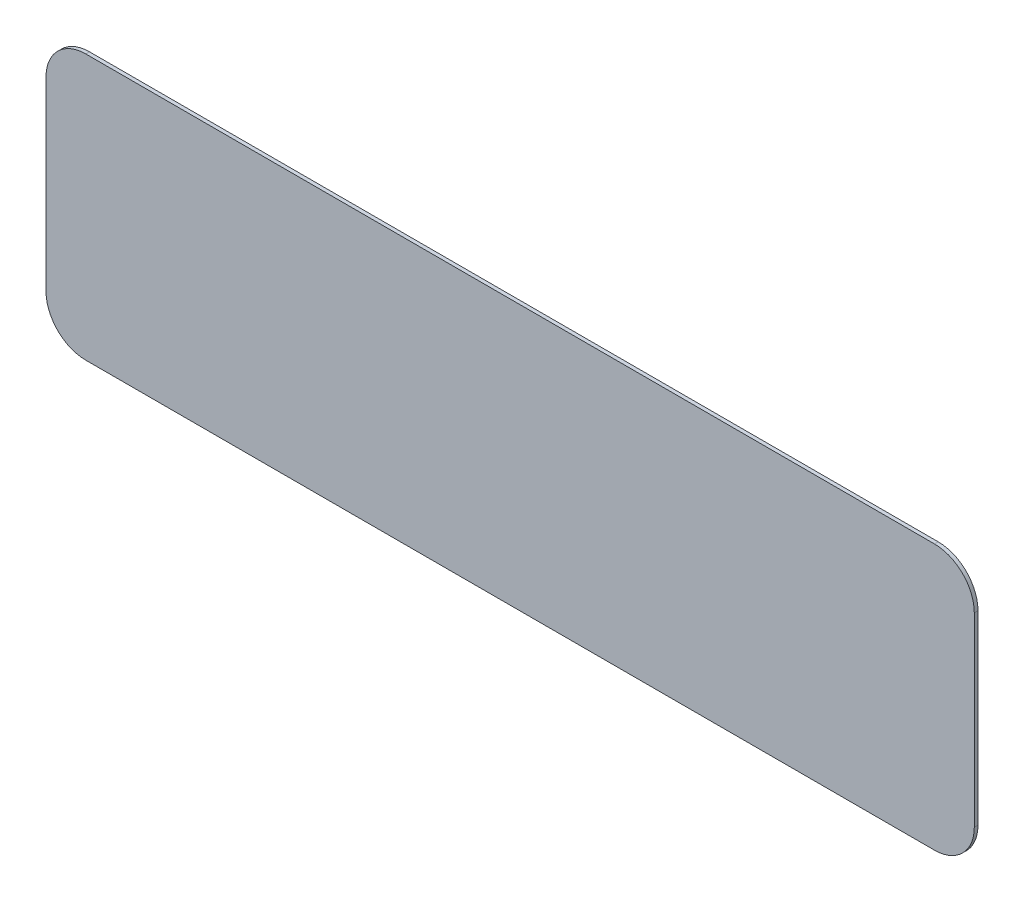
from build123d import *

# Parameters (mm, degrees)
BOSS_EXTRUDE1_DEPTH = 0.1778


with BuildPart() as part:
    # Sketch1 → Boss-Extrude1 (new body)
    with BuildSketch(Plane.XY):
        with BuildLine():
            Line((-20.32, -6.35), (20.32, -6.35))
            ThreePointArc((20.32, -6.35), (21.667038418, -5.792038418), (22.225, -4.445))
            Line((22.225, -4.445), (22.225, 4.445))
            ThreePointArc((22.225, 4.445), (21.667038418, 5.792038418), (20.32, 6.35))
            Line((20.32, 6.35), (-20.32, 6.35))
            ThreePointArc((-20.32, 6.35), (-21.667038418, 5.792038418), (-22.225, 4.445))
            Line((-22.225, 4.445), (-22.225, -4.445))
            ThreePointArc((-22.225, -4.445), (-21.667038418, -5.792038418), (-20.32, -6.35))
        make_face()
    extrude(amount=BOSS_EXTRUDE1_DEPTH)


solid = part.part
